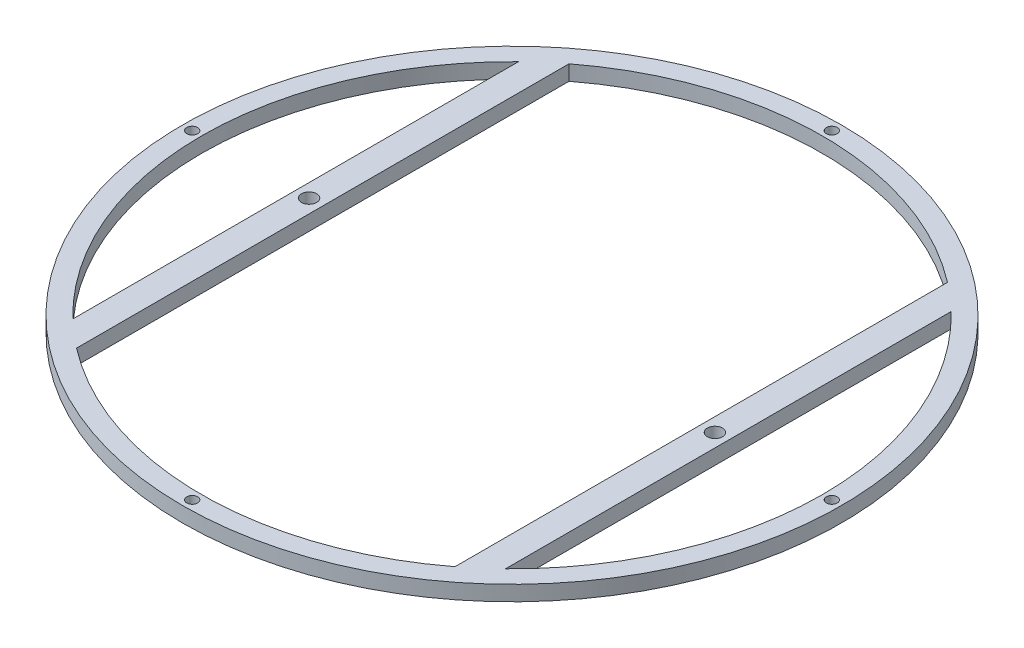
from build123d import *

# Parameters (mm, degrees)
SKETCH1_R           = 76
BOSS_EXTRUDE1_DEPTH = 3.5
CUT_EXTRUDE1_DEPTH  = 4.5
SKETCH3_R           = 1.75
CUT_EXTRUDE2_DEPTH  = 4.5
SKETCH5_R           = 1.25
CUT_EXTRUDE3_DEPTH  = 4.5


with BuildPart() as part:
    # Sketch1 → Boss-Extrude1 (new body)
    with BuildSketch(Plane(origin=(0, 0, 0), x_dir=(1, 0, 0), z_dir=(0, 1, 0))):
        Circle(SKETCH1_R)
    extrude(amount=BOSS_EXTRUDE1_DEPTH)

    # Sketch2 → Cut-Extrude1 (cut, through all)
    with BuildSketch(Plane(origin=(0, 3.5, 0), x_dir=(1, 0, 0), z_dir=(0, 1, 0))):
        with BuildLine():
            Line((-49.893169191, 51.382751627), (-49.893169191, -51.382751627))
            ThreePointArc((-49.893169191, -51.382751627), (-71.620635969, 0), (-49.893169191, 51.382751627))
        make_face()
        with BuildLine():
            Line((-43.644274738, 56.786378466), (-43.644274738, -56.786378466))
            ThreePointArc((-43.644274738, -56.786378466), (0, -71.620635969), (43.644274738, -56.786378466))
            Line((43.644274738, -56.786378466), (43.644274738, 56.786378466))
            ThreePointArc((43.644274738, 56.786378466), (0, 71.620635969), (-43.644274738, 56.786378466))
        make_face()
        with BuildLine():
            Line((49.893169191, 51.382751627), (49.893169191, -51.382751627))
            ThreePointArc((49.893169191, -51.382751627), (71.620635969, 0), (49.893169191, 51.382751627))
        make_face()
    extrude(amount=-CUT_EXTRUDE1_DEPTH, mode=Mode.SUBTRACT)

    # Sketch3 → Cut-Extrude2 (cut, through all)
    with BuildSketch(Plane(origin=(0, 3.5, 0), x_dir=(1, 0, 0), z_dir=(0, 1, 0))):
        with Locations((-46.793169191, 0)):
            Circle(SKETCH3_R)
        with Locations((46.793169191, 0)):
            Circle(SKETCH3_R)
    extrude(amount=-CUT_EXTRUDE2_DEPTH, mode=Mode.SUBTRACT)

    # Sketch5 → Cut-Extrude3 (cut, through all)
    with BuildSketch(Plane(origin=(0, 3.5, 0), x_dir=(1, 0, 0), z_dir=(0, 1, 0))):
        with Locations((0, -73.75)):
            Circle(SKETCH5_R)
        with Locations((-73.75, 0)):
            Circle(SKETCH5_R)
        with Locations((73.75, 0)):
            Circle(SKETCH5_R)
        with Locations((0, 73.75)):
            Circle(SKETCH5_R)
    extrude(amount=-CUT_EXTRUDE3_DEPTH, mode=Mode.SUBTRACT)


solid = part.part
